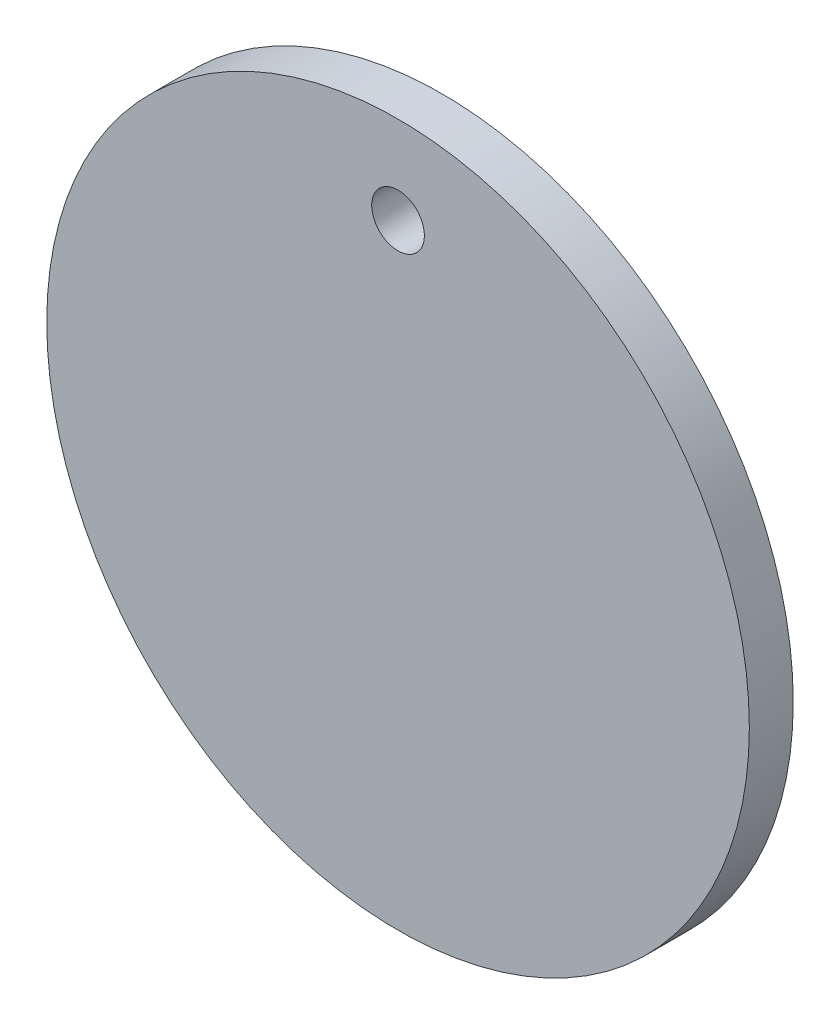
from build123d import *

# Parameters (mm, degrees)
SKETCH1_R           = 25.4
SKETCH1_R_2         = 1.905
BOSS_EXTRUDE1_DEPTH = 3.175


with BuildPart() as part:
    # Sketch1 → Boss-Extrude1 (new body)
    with BuildSketch(Plane.XY):
        Circle(SKETCH1_R)
        with Locations((0, 19.05)):
            Circle(SKETCH1_R_2, mode=Mode.SUBTRACT)
    extrude(amount=BOSS_EXTRUDE1_DEPTH)


solid = part.part
